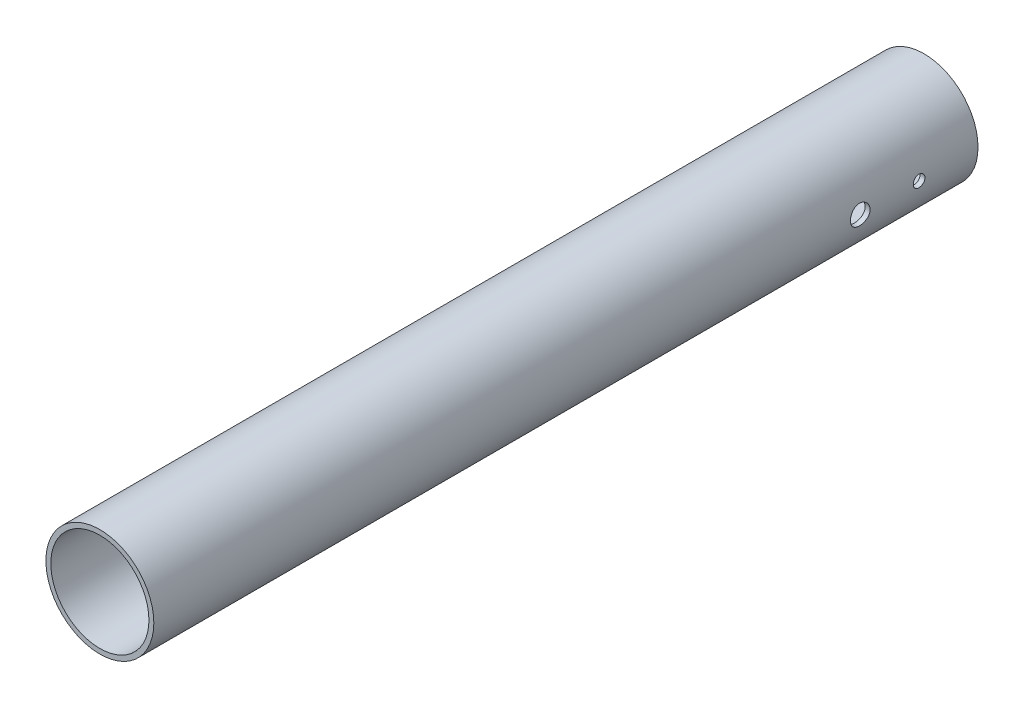
from build123d import *

# Parameters (mm, degrees)
SKETCH2_R                        = 17.4625
SKETCH2_R_2                      = 15.875
BOSS_EXTRUDE1_DEPTH              = 266.7
F_6_CLEARANCE_HOLE1_D            = 3.7973
F_1_4_0_25_DIAMETER_HOLE1_REACH  = 36.925
F_1_4_0_25_DIAMETER_HOLE1_BORE_R = 3.175


with BuildPart() as part:
    # Sketch2 → Boss-Extrude1 (new body)
    with BuildSketch(Plane.XY):
        Circle(SKETCH2_R)
        Circle(SKETCH2_R_2, mode=Mode.SUBTRACT)
    extrude(amount=BOSS_EXTRUDE1_DEPTH)

    # #6 Clearance Hole1 (through all)
    with Locations(Plane(origin=(17.4625, 0, 19.05), x_dir=(0, 1, 0), z_dir=(1, 0, 0))):
        with Locations((0, 0)):
            Hole(F_6_CLEARANCE_HOLE1_D / 2)

    # 1/4 (0.25) Diameter Hole1 bore (on position points) → 1/4 (0.25) Diameter Hole1 (cut, up to next)
    with BuildSketch(Plane(origin=(17.4625, 0, 38.1), x_dir=(0, 1, 0), z_dir=(1, 0, 0)), mode=Mode.PRIVATE) as f_1_4_0_25_diameter_hole1_sk1:
        Circle(F_1_4_0_25_DIAMETER_HOLE1_BORE_R)
    f_1_4_0_25_diameter_hole1_tool1 = extrude(f_1_4_0_25_diameter_hole1_sk1.sketch, amount=-F_1_4_0_25_DIAMETER_HOLE1_REACH, mode=Mode.PRIVATE) & part.part
    add(f_1_4_0_25_diameter_hole1_tool1.solids().sort_by_distance((17.4625, 0, 38.1))[0], mode=Mode.SUBTRACT)


solid = part.part
